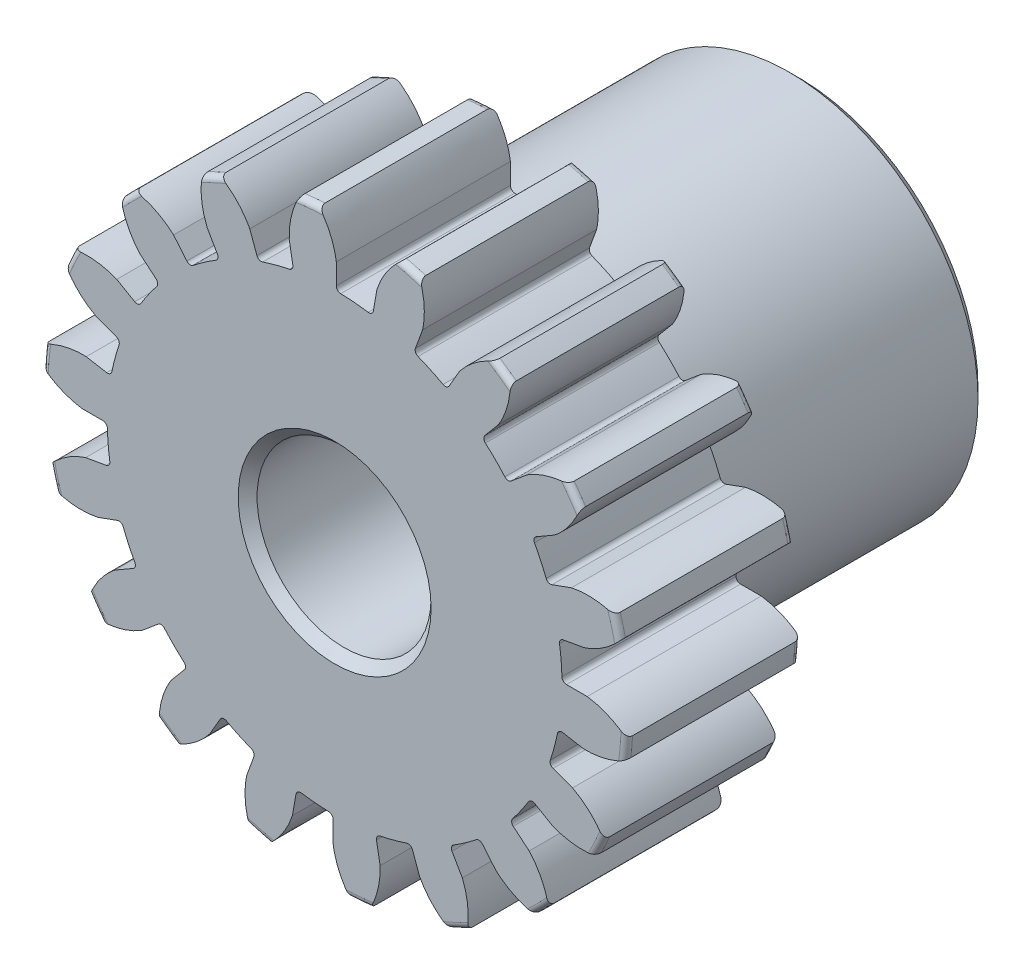
from build123d import *

# Parameters (mm, degrees)
SKETCH1_R                = 8.001
BOSS_EXTRUDE1_DEPTH      = 4.7625
SKETCH2_W                = 7.9375
SKETCH2_H                = 5.159375
FILLET2_R                = 0.16002
CUT_EXTRUDE1_DEPTH       = 13.7
FILLET1_R                = 0.124571421
CIRPATTERN1_COUNT        = 18
FILLET1_OF_CIRPATTERN1_R = 0.124571421
SKETCH5_R                = 2.38125
CUT_EXTRUDE2_DEPTH       = 13.7
CHAMFER1_SIZE            = 0.25796875


with BuildPart() as part:
    # Sketch1 → Boss-Extrude1 (new body)
    with BuildSketch(Plane.XY):
        Circle(SKETCH1_R)
    extrude(amount=-BOSS_EXTRUDE1_DEPTH)

    # Sketch2 → Revolve1 (revolve)
    with BuildSketch(Plane(origin=(0, 0, 0), x_dir=(0, 0, -1), z_dir=(1, 0, 0))):
        with Locations((8.73125, 2.5796875)):
            Rectangle(SKETCH2_W, SKETCH2_H)
    revolve(axis=Axis((0, 0, -4.7625), (0, 0, -1)))

    # Fillet2
    fillet2_edges = [part.edges().sort_by_distance(p)[0] for p in [
        (-8.001, 0, 0),
        (-8.001, 0, -4.7625),
        (0, -5.159375, -4.7625),
    ]]
    fillet(fillet2_edges, radius=FILLET2_R)

    # Sketch4 → Cut-Extrude1 (cut, through all)
    with BuildSketch(Plane.XY):
        with BuildLine():
            Line((0.043858905, 6.909917778), (0.043858905, 6.219692942))
            ThreePointArc((0.043858905, 6.219692942), (0.5420967, 6.196179069), (1.036848258, 6.132817426))
            Line((1.036848258, 6.132817426), (1.156704821, 6.812556148))
            add(Edge.make_bspline(
                [(1.8294284, 7.815882716), (1.34360415, 7.391518367), (1.156704821, 6.812556148)],
                knots=[0, 0, 0, 1, 1, 1], degree=2))
            ThreePointArc((1.8294284, 7.815882716), (0.69961219, 7.996585126), (-0.444418211, 8.014818985))
            add(Edge.make_bspline(
                [(-0.444418211, 8.014818985), (-0.039665023, 7.512539023), (0.043858905, 6.909917778)],
                knots=[0, 0, 0, 1, 1, 1], degree=2))
        make_face()
    cut_extrude1 = extrude(amount=-CUT_EXTRUDE1_DEPTH, mode=Mode.SUBTRACT)

    # Fillet1
    fillet1_edges = [part.edges().sort_by_distance(p)[0] for p in [
        (1.036848258, 6.132817426, -2.38125),
        (0.043858905, 6.219692942, -2.38125),
    ]]
    fillet(fillet1_edges, radius=FILLET1_R)

    # CirPattern1: Cut-Extrude1 ×18 about axis
    cirpattern1_axis = Axis((0, 0, -4.7625), (0, 0, 1))
    for i in range(1, CIRPATTERN1_COUNT):
        add(cut_extrude1.rotate(cirpattern1_axis, i * 360 / CIRPATTERN1_COUNT), mode=Mode.SUBTRACT)

    # Fillet1 of CirPattern1
    fillet1_of_cirpattern1_edges = [part.edges().sort_by_distance(p)[0] for p in [
        (-1.123228438, 6.11758627, -2.38125),
        (-2.086046382, 5.85960019, -2.38125),
        (-3.147827207, 5.364483923, -2.38125),
        (-3.964343689, 4.792753176, -2.38125),
        (-4.792751558, 3.964345645, -2.38125),
        (-5.364482639, 3.147829397, -2.38125),
        (-5.859599338, 2.086048774, -2.38125),
        (-6.117585811, 1.123230934, -2.38125),
        (-6.219692959, -0.043856366, -2.38125),
        (-6.132817849, -1.036845755, -2.38125),
        (-5.829599817, -2.168471781, -2.38125),
        (-5.408341544, -3.071863545, -2.38125),
        (-4.736370901, -4.031537496, -2.38125),
        (-4.031539429, -4.736369255, -2.38125),
        (-3.071865752, -5.40834029, -2.38125),
        (-2.168474161, -5.829598932, -2.38125),
        (-1.036848258, -6.132817426, -2.38125),
        (-0.043858905, -6.219692942, -2.38125),
        (1.123228438, -6.11758627, -2.38125),
        (2.086046382, -5.85960019, -2.38125),
        (3.147827207, -5.364483923, -2.38125),
        (3.964343689, -4.792753176, -2.38125),
        (4.792751558, -3.964345645, -2.38125),
        (5.364482639, -3.147829397, -2.38125),
        (5.859599338, -2.086048774, -2.38125),
        (6.117585811, -1.123230934, -2.38125),
        (6.219692959, 0.043856366, -2.38125),
        (6.132817849, 1.036845755, -2.38125),
        (5.829599817, 2.168471781, -2.38125),
        (5.408341544, 3.071863545, -2.38125),
        (4.736370901, 4.031537496, -2.38125),
        (4.031539429, 4.736369255, -2.38125),
        (3.071865752, 5.40834029, -2.38125),
        (2.168474161, 5.829598932, -2.38125),
    ]]
    fillet(fillet1_of_cirpattern1_edges, radius=FILLET1_OF_CIRPATTERN1_R)

    # Sketch5 → Cut-Extrude2 (cut, through all)
    with BuildSketch(Plane.XY):
        Circle(SKETCH5_R)
    extrude(amount=-CUT_EXTRUDE2_DEPTH, mode=Mode.SUBTRACT)

    # Chamfer1
    chamfer1_edges = [part.edges().sort_by_distance(p)[0] for p in [
        (0, -5.159375, -12.7),
        (-2.38125, 0, -12.7),
        (-2.38125, 0, 0),
    ]]
    chamfer(chamfer1_edges, length=CHAMFER1_SIZE)


solid = part.part
